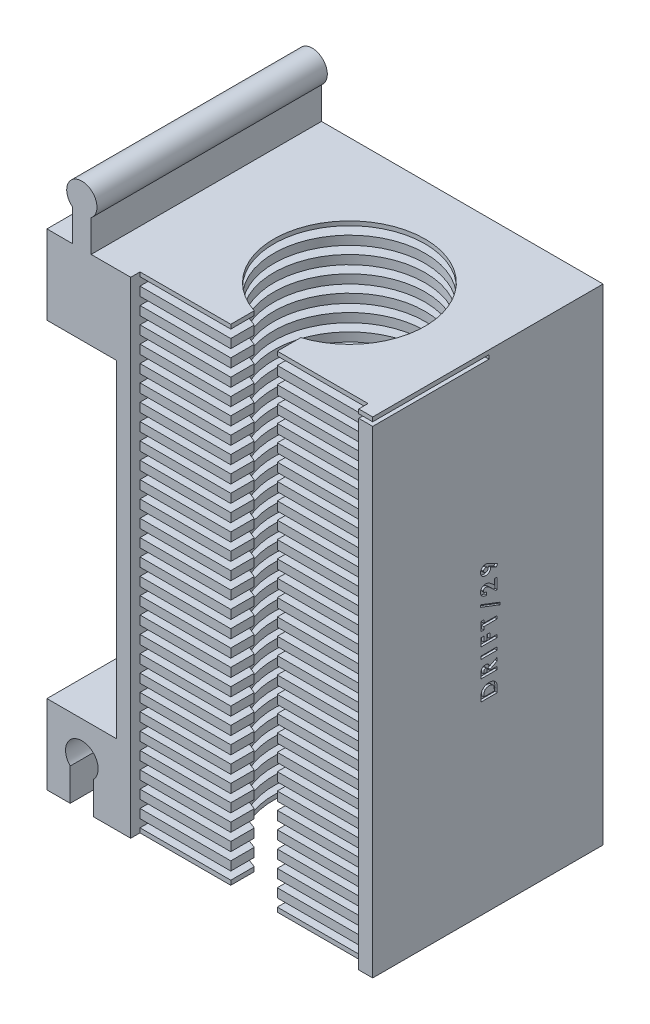
from build123d import *

# Parameters (mm, degrees)
ESQUISSE1_W              = 55
ESQUISSE1_H              = 106.55
BOSS_EXTRU_2_DEPTH       = 49.5
ESQUISSE6_W              = 49
ESQUISSE6_H              = 101.75
ENL_V_MAT_EXTRU_2_DEPTH  = 47
ESQUISSE7_W              = 49
ESQUISSE7_H              = 1.9
BOSS_EXTRU_3_DEPTH       = 45
ESQUISSE8_R              = 16.25
ENL_V_MAT_EXTRU_4_DEPTH  = 107.55
ESQUISSE9_W              = 10
ESQUISSE9_H              = 5.038353904
ENL_V_MAT_EXTRU_5_DEPTH  = 107.55
ESQUISSE11_W             = 55
ESQUISSE11_H             = 49.5
ENL_V_MAT_EXTRU_6_DEPTH  = 4.8
ESQUISSE14_W             = 15
ESQUISSE14_H             = 17.95
BOSS_EXTRU_5_DEPTH       = 49.5
ESQUISSE15_W             = 15
ESQUISSE15_H             = 17.95
BOSS_EXTRU_6_DEPTH       = 49.5
ESQUISSE16_W             = 15
ESQUISSE16_H             = 17
BOSS_EXTRU_7_DEPTH       = 49.5
ESQUISSE17_W             = 15
ESQUISSE17_H             = 17
BOSS_EXTRU_8_DEPTH       = 49.5
ENL_V_MAT_EXTRU_8_DEPTH  = 50.5
BOSS_EXTRU_9_DEPTH       = 49.5
ENL_V_MAT_EXTRU_10_DEPTH = 0.95
ESQUISSE22_W             = 5
ESQUISSE22_H             = 49.5
ENL_V_MAT_EXTRU_11_DEPTH = 0.95
BOSS_EXTRU_10_DEPTH      = 3.6
ESQUISSE24_W             = 49
ESQUISSE24_H             = 1.7
ENL_V_MAT_EXTRU_12_DEPTH = 45
ESQUISSE25_W             = 15
ESQUISSE25_H             = 49.5
ENL_V_MAT_EXTRU_13_DEPTH = 3.6
ESQUISSE26_W             = 5.5
ESQUISSE26_H             = 49.5
BOSS_EXTRU_11_DEPTH      = 3.6
ESQUISSE27_W             = 3.5
ESQUISSE27_H             = 0.628205128
ENL_V_MAT_EXTRU_15_DEPTH = 0.5
ESQUISSE28_W             = 15
ESQUISSE28_H             = 49.5
ENL_V_MAT_EXTRU_16_DEPTH = 18
ESQUISSE29_W             = 15
ESQUISSE29_H             = 49.5
ENL_V_MAT_EXTRU_17_DEPTH = 30.651737691
ENL_V_MAT_EXTRU_18_DEPTH = 0.05
ESQUISSE31_W             = 25
ESQUISSE31_H             = 0.85
ENL_V_MAT_EXTRU_19_DEPTH = 4.0000001


with BuildPart() as part:
    # Esquisse1 → Boss.-Extru.2 (new body)
    with BuildSketch(Plane.XY):
        with Locations((7.352262443, -28.968325792)):
            Rectangle(ESQUISSE1_W, ESQUISSE1_H)
    extrude(amount=BOSS_EXTRU_2_DEPTH)

    # Esquisse6 → Enlèv. mat.-Extru.2 (cut)
    with BuildSketch(Plane.XY.offset(49.5)):
        with Locations((7.352262443, -31.368325792)):
            Rectangle(ESQUISSE6_W, ESQUISSE6_H)
    extrude(amount=-ENL_V_MAT_EXTRU_2_DEPTH, mode=Mode.SUBTRACT)

    # Esquisse7 → Boss.-Extru.3 (add)
    with BuildSketch(Plane.XY.offset(2.5)):
        with Locations((7.352262443, -81.293325792)):
            Rectangle(ESQUISSE7_W, ESQUISSE7_H)
        with Locations((7.352262443, -77.693325792)):
            Rectangle(ESQUISSE7_W, ESQUISSE7_H)
        with Locations((7.352262443, -74.093325792)):
            Rectangle(ESQUISSE7_W, ESQUISSE7_H)
        with Locations((7.352262443, -70.493325792)):
            Rectangle(ESQUISSE7_W, ESQUISSE7_H)
        with Locations((7.352262443, -66.893325792)):
            Rectangle(ESQUISSE7_W, ESQUISSE7_H)
        with Locations((7.352262443, -63.293325792)):
            Rectangle(ESQUISSE7_W, ESQUISSE7_H)
        with Locations((7.352262443, -59.693325792)):
            Rectangle(ESQUISSE7_W, ESQUISSE7_H)
        with Locations((7.352262443, -56.093325792)):
            Rectangle(ESQUISSE7_W, ESQUISSE7_H)
        with Locations((7.352262443, -52.493325792)):
            Rectangle(ESQUISSE7_W, ESQUISSE7_H)
        with Locations((7.352262443, -48.893325792)):
            Rectangle(ESQUISSE7_W, ESQUISSE7_H)
        with Locations((7.352262443, -45.293325792)):
            Rectangle(ESQUISSE7_W, ESQUISSE7_H)
        with Locations((7.352262443, -41.693325792)):
            Rectangle(ESQUISSE7_W, ESQUISSE7_H)
        with Locations((7.352262443, -38.093325792)):
            Rectangle(ESQUISSE7_W, ESQUISSE7_H)
        with Locations((7.352262443, -34.493325792)):
            Rectangle(ESQUISSE7_W, ESQUISSE7_H)
        with Locations((7.352262443, -30.893325792)):
            Rectangle(ESQUISSE7_W, ESQUISSE7_H)
        with Locations((7.352262443, -27.293325792)):
            Rectangle(ESQUISSE7_W, ESQUISSE7_H)
        with Locations((7.352262443, -23.693325792)):
            Rectangle(ESQUISSE7_W, ESQUISSE7_H)
        with Locations((7.352262443, -20.093325792)):
            Rectangle(ESQUISSE7_W, ESQUISSE7_H)
        with Locations((7.352262443, -16.493325792)):
            Rectangle(ESQUISSE7_W, ESQUISSE7_H)
        with Locations((7.352262443, -12.893325792)):
            Rectangle(ESQUISSE7_W, ESQUISSE7_H)
        with Locations((7.352262443, -9.293325792)):
            Rectangle(ESQUISSE7_W, ESQUISSE7_H)
        with Locations((7.352262443, -5.693325792)):
            Rectangle(ESQUISSE7_W, ESQUISSE7_H)
        with Locations((7.352262443, -2.093325792)):
            Rectangle(ESQUISSE7_W, ESQUISSE7_H)
        with Locations((7.352262443, 1.506674208)):
            Rectangle(ESQUISSE7_W, ESQUISSE7_H)
        with Locations((7.352262443, 5.106674208)):
            Rectangle(ESQUISSE7_W, ESQUISSE7_H)
        with Locations((7.352262443, 8.706674208)):
            Rectangle(ESQUISSE7_W, ESQUISSE7_H)
        with Locations((7.352262443, 12.306674208)):
            Rectangle(ESQUISSE7_W, ESQUISSE7_H)
        with Locations((7.352262443, 15.906674208)):
            Rectangle(ESQUISSE7_W, ESQUISSE7_H)
        with Locations((7.352262443, 19.506674208)):
            Rectangle(ESQUISSE7_W, ESQUISSE7_H)
    extrude(amount=BOSS_EXTRU_3_DEPTH)

    # Esquisse8 → Enlèv. mat.-Extru.4 (cut, through all)
    with BuildSketch(Plane.XZ.offset(82.243325792)):
        with Locations((7.352262443, 27)):
            Circle(ESQUISSE8_R)
    extrude(amount=-ENL_V_MAT_EXTRU_4_DEPTH, mode=Mode.SUBTRACT)

    # Esquisse9 → Enlèv. mat.-Extru.5 (cut, through all)
    with BuildSketch(Plane.XZ.offset(82.243325792)):
        with Locations((7.352262443, 44.980823048)):
            Rectangle(ESQUISSE9_W, ESQUISSE9_H)
    extrude(amount=-ENL_V_MAT_EXTRU_5_DEPTH, mode=Mode.SUBTRACT)

    # Esquisse11 → Enlèv. mat.-Extru.6 (cut)
    with BuildSketch(Plane(origin=(0, 24.306674208, 0), x_dir=(1, 0, 0), z_dir=(0, 1, 0))):
        with Locations((7.352262443, -24.75)):
            Rectangle(ESQUISSE11_W, ESQUISSE11_H)
    extrude(amount=-ENL_V_MAT_EXTRU_6_DEPTH, mode=Mode.SUBTRACT)

    # Esquisse14 → Boss.-Extru.5 (add)
    with BuildSketch(Plane.XY.offset(49.5)):
        with Locations((42.352262443, -73.268325792)):
            Rectangle(ESQUISSE14_W, ESQUISSE14_H)
    extrude(amount=-BOSS_EXTRU_5_DEPTH)

    # Esquisse15 → Boss.-Extru.6 (add)
    with BuildSketch(Plane.XY.offset(49.5)):
        with Locations((-27.647737557, -73.268325792)):
            Rectangle(ESQUISSE15_W, ESQUISSE15_H)
    extrude(amount=-BOSS_EXTRU_6_DEPTH)

    # Esquisse16 → Boss.-Extru.7 (add)
    with BuildSketch(Plane.XY.offset(49.5)):
        with Locations((42.352262443, 11.006674208)):
            Rectangle(ESQUISSE16_W, ESQUISSE16_H)
    extrude(amount=-BOSS_EXTRU_7_DEPTH)

    # Esquisse17 → Boss.-Extru.8 (add)
    with BuildSketch(Plane.XY.offset(49.5)):
        with Locations((-27.647737557, 11.006674208)):
            Rectangle(ESQUISSE17_W, ESQUISSE17_H)
    extrude(amount=-BOSS_EXTRU_8_DEPTH)

    # Esquisse18 → Enlèv. mat.-Extru.8 (cut, through all)
    with BuildSketch(Plane.XY.offset(49.5)):
        with BuildLine():
            Line((44.852262443, -74.343325792), (44.852262443, -82.243325792))
            Line((44.852262443, -82.243325792), (39.852262443, -82.243325792))
            Line((39.852262443, -82.243325792), (39.852262443, -74.343325792))
            ThreePointArc((39.852262443, -74.343325792), (42.352262443, -68.393836049), (44.852262443, -74.343325792))
        make_face()
        with BuildLine():
            Line((-30.147737557, -82.243325792), (-25.147737557, -82.243325792))
            Line((-25.147737557, -82.243325792), (-25.147737557, -74.343325792))
            ThreePointArc((-25.147737557, -74.343325792), (-27.647737557, -68.393836049), (-30.147737557, -74.343325792))
            Line((-30.147737557, -74.343325792), (-30.147737557, -82.243325792))
        make_face()
    extrude(amount=-ENL_V_MAT_EXTRU_8_DEPTH, mode=Mode.SUBTRACT)

    # Esquisse20 → Boss.-Extru.9 (add)
    with BuildSketch(Plane.XY.offset(49.5)):
        with BuildLine():
            Line((-29.647737557, 29.946674208), (-29.647737557, 19.506674208))
            Line((-29.647737557, 19.506674208), (-25.647737557, 19.506674208))
            Line((-25.647737557, 19.506674208), (-25.647737557, 29.946674208))
            ThreePointArc((-25.647737557, 29.946674208), (-27.647737557, 35.7584119), (-29.647737557, 29.946674208))
        make_face()
        with BuildLine():
            Line((40.352262443, 19.506674208), (40.352262443, 29.946674208))
            ThreePointArc((40.352262443, 29.946674208), (42.352262443, 35.7584119), (44.352262443, 29.946674208))
            Line((44.352262443, 29.946674208), (44.352262443, 19.506674208))
            Line((44.352262443, 19.506674208), (40.352262443, 19.506674208))
        make_face()
    extrude(amount=-BOSS_EXTRU_9_DEPTH)

    # Esquisse10 → Enlèv. mat.-Extru.10 (cut)
    with BuildSketch(Plane.XZ.offset(82.243325792)):
        with BuildLine():
            Line((31.852262443, 47.5), (12.352262443, 47.5))
            Line((12.352262443, 47.5), (12.352262443, 42.461646096))
            ThreePointArc((12.352262443, 42.461646096), (7.352262443, 10.75), (2.352262443, 42.461646096))
            Line((2.352262443, 42.461646096), (2.352262443, 47.5))
            Line((2.352262443, 47.5), (-17.147737557, 47.5))
            Line((-17.147737557, 47.5), (-17.147737557, 49.5))
            Line((-17.147737557, 49.5), (-20.147737557, 49.5))
            Line((-20.147737557, 49.5), (-20.147737557, 0))
            Line((-20.147737557, 0), (34.852262443, 0))
            Line((34.852262443, 0), (34.852262443, 49.5))
            Line((34.852262443, 49.5), (31.852262443, 49.5))
            Line((31.852262443, 49.5), (31.852262443, 47.5))
        make_face()
    extrude(amount=-ENL_V_MAT_EXTRU_10_DEPTH, mode=Mode.SUBTRACT)

    # Esquisse22 → Enlèv. mat.-Extru.11 (cut)
    with BuildSketch(Plane.XZ.offset(82.243325792)):
        with Locations((47.352262443, 24.75)):
            Rectangle(ESQUISSE22_W, ESQUISSE22_H)
        with Locations((37.352262443, 24.75)):
            Rectangle(ESQUISSE22_W, ESQUISSE22_H)
        with Locations((-32.647737557, 24.75)):
            Rectangle(ESQUISSE22_W, ESQUISSE22_H)
        with Locations((-22.647737557, 24.75)):
            Rectangle(ESQUISSE22_W, ESQUISSE22_H)
    extrude(amount=-ENL_V_MAT_EXTRU_11_DEPTH, mode=Mode.SUBTRACT)

    # Esquisse23 → Boss.-Extru.10 (add)
    with BuildSketch(Plane(origin=(0, 19.506674208, 0), x_dir=(1, 0, 0), z_dir=(0, 1, 0))):
        with BuildLine():
            Line((40.352262443, -49.5), (40.352262443, 0))
            Line((40.352262443, 0), (-25.647737557, 0))
            Line((-25.647737557, 0), (-25.647737557, -49.5))
            Line((-25.647737557, -49.5), (-17.147737557, -49.5))
            Line((-17.147737557, -49.5), (-17.147737557, -47.5))
            Line((-17.147737557, -47.5), (2.352262443, -47.5))
            Line((2.352262443, -47.5), (2.352262443, -42.461646096))
            ThreePointArc((2.352262443, -42.461646096), (7.352262443, -10.75), (12.352262443, -42.461646096))
            Line((12.352262443, -42.461646096), (12.352262443, -47.5))
            Line((12.352262443, -47.5), (31.852262443, -47.5))
            Line((31.852262443, -47.5), (31.852262443, -49.5))
            Line((31.852262443, -49.5), (40.352262443, -49.5))
        make_face()
    extrude(amount=BOSS_EXTRU_10_DEPTH)

    # Esquisse24 → Enlèv. mat.-Extru.12 (cut)
    with BuildSketch(Plane.XY.offset(47.5)):
        with Locations((7.352262443, 21.306674208)):
            Rectangle(ESQUISSE24_W, ESQUISSE24_H)
    extrude(amount=-ENL_V_MAT_EXTRU_12_DEPTH, mode=Mode.SUBTRACT)

    # Esquisse25 → Enlèv. mat.-Extru.13 (cut)
    with BuildSketch(Plane.XZ.offset(-2.506674208)):
        with Locations((-27.647737557, 24.75)):
            Rectangle(ESQUISSE25_W, ESQUISSE25_H)
        with Locations((42.352262443, 24.75)):
            Rectangle(ESQUISSE25_W, ESQUISSE25_H)
    extrude(amount=-ENL_V_MAT_EXTRU_13_DEPTH, mode=Mode.SUBTRACT)

    # Esquisse26 → Boss.-Extru.11 (add)
    with BuildSketch(Plane(origin=(0, 19.506674208, 0), x_dir=(1, 0, 0), z_dir=(0, 1, 0))):
        with Locations((-32.397737557, -24.75)):
            Rectangle(ESQUISSE26_W, ESQUISSE26_H)
        with Locations((47.102262443, -24.75)):
            Rectangle(ESQUISSE26_W, ESQUISSE26_H)
    extrude(amount=BOSS_EXTRU_11_DEPTH)

    # Esquisse27 → Enlèv. mat.-Extru.15 (cut)
    with BuildSketch(Plane(origin=(34.852262443, 0, 0), x_dir=(0, 0, -1), z_dir=(1, 0, 0))):
        with BuildLine():
            Line((-26.25, -41.581146305), (-26.25, -40.789579798))
            add(Edge.make_bspline(
                [(-26.25, -40.789579798), (-26.249578594, -40.727866572), (-26.248764011, -40.608574207), (-26.239233964, -40.435767762), (-26.225241045, -40.274959028), (-26.203820297, -40.126514303), (-26.178974202, -39.989890609), (-26.145644783, -39.866124289), (-26.107640591, -39.754317891), (-26.062804681, -39.65338554), (-26.010558183, -39.561239848), (-25.952352997, -39.473745665), (-25.886064826, -39.391073342), (-25.812970397, -39.312063093), (-25.731733047, -39.237734455), (-25.643698202, -39.166849619), (-25.547589281, -39.101144161), (-25.445710659, -39.038631948), (-25.337630589, -38.98209797), (-25.224269024, -38.932786922), (-25.106355489, -38.891478757), (-24.983764318, -38.857913735), (-24.856902477, -38.831158538), (-24.72551397, -38.812438466), (-24.589720442, -38.800865531), (-24.4976865, -38.799691554), (-24.450921474, -38.799095023)],
                knots=[0, 0, 0, 0, 0.000185117, 0.000357834, 0.000519065, 0.000669183, 0.000807653, 0.000935374, 0.001053334, 0.001161611, 0.001266144, 0.001370762, 0.001476536, 0.001583695, 0.001693351, 0.00180657, 0.001922483, 0.002042366, 0.002164984, 0.002288073, 0.002412914, 0.002539466, 0.002669135, 0.002801605, 0.002937385, 0.003077654, 0.003077654, 0.003077654, 0.003077654], degree=3))
            add(Edge.make_bspline(
                [(-24.450921474, -38.799095023), (-24.384932979, -38.800657062), (-24.255030763, -38.803732029), (-24.064400757, -38.829633833), (-23.881662884, -38.87152582), (-23.708246589, -38.930429758), (-23.545696172, -39.003454873), (-23.396878133, -39.09069155), (-23.262591281, -39.190860698), (-23.143504152, -39.302795331), (-23.04114743, -39.423993307), (-22.953485402, -39.549942339), (-22.884360039, -39.681869876), (-22.840513664, -39.79811532), (-22.813270001, -39.898917402), (-22.797083391, -39.987411224), (-22.782639367, -40.087999175), (-22.769738179, -40.201348242), (-22.761139953, -40.327447269), (-22.755119024, -40.466317598), (-22.750668347, -40.617777023), (-22.75022862, -40.722969702), (-22.75, -40.777660728)],
                knots=[0, 0, 0, 0, 0.000197895, 0.000389568, 0.000575968, 0.000759549, 0.000938093, 0.001109685, 0.001275991, 0.00143967, 0.001598838, 0.001751113, 0.001899136, 0.002044464, 0.002122868, 0.002212109, 0.002314138, 0.002427722, 0.002554253, 0.002693218, 0.002844719, 0.003008787, 0.003008787, 0.003008787, 0.003008787], degree=3))
            Line((-22.75, -40.777660728), (-22.75, -41.581146305))
            Line((-22.75, -41.581146305), (-26.25, -41.581146305))
        make_face()
        with BuildLine():
            Line((-25.621794872, -40.952941176), (-23.378205128, -40.952941176))
            Line((-23.378205128, -40.952941176), (-23.378205128, -40.624816176))
            add(Edge.make_bspline(
                [(-23.378205128, -40.624816176), (-23.378394152, -40.58578111), (-23.378757652, -40.51071505), (-23.383752105, -40.402204241), (-23.391862503, -40.302063523), (-23.403859003, -40.210161726), (-23.418293863, -40.126287573), (-23.436147882, -40.050747014), (-23.457859729, -39.983391161), (-23.483447361, -39.923664568), (-23.512661318, -39.869135507), (-23.546774213, -39.818618742), (-23.584684458, -39.769863909), (-23.627472703, -39.723772091), (-23.674581701, -39.680171713), (-23.726251594, -39.639319951), (-23.782325449, -39.60067176), (-23.843099544, -39.565219106), (-23.907932147, -39.532822285), (-23.976195242, -39.504082673), (-24.04845732, -39.480253294), (-24.124041919, -39.460447773), (-24.20360709, -39.446294483), (-24.286563503, -39.434585335), (-24.373239826, -39.428548928), (-24.432217292, -39.427720468), (-24.462139423, -39.427300151)],
                knots=[0, 0, 0, 0, 0.000117096, 0.00022518, 0.000325793, 0.00041841, 0.000503133, 0.000581017, 0.00065108, 0.000715155, 0.0007757, 0.00083637, 0.000897801, 0.000960813, 0.001024815, 0.001090185, 0.001158251, 0.001228957, 0.001301074, 0.001375555, 0.001450937, 0.001529162, 0.001609745, 0.001693235, 0.001780402, 0.001870171, 0.001870171, 0.001870171, 0.001870171], degree=3))
            add(Edge.make_bspline(
                [(-24.462139423, -39.427300151), (-24.507993301, -39.428134279), (-24.597404811, -39.429760763), (-24.727617239, -39.445544279), (-24.850078276, -39.470976128), (-24.964473331, -39.508023303), (-25.071529664, -39.55358164), (-25.169867721, -39.611510018), (-25.261099367, -39.678289281), (-25.314608967, -39.731127033), (-25.341346154, -39.757528516)],
                knots=[0, 0, 0, 0, 0.000137507, 0.000268129, 0.000392852, 0.000512141, 0.000628325, 0.00074112, 0.000853862, 0.000966454, 0.000966454, 0.000966454, 0.000966454], degree=3))
            add(Edge.make_bspline(
                [(-25.341346154, -39.757528516), (-25.364130624, -39.78356071), (-25.410665325, -39.836728519), (-25.466425797, -39.93007372), (-25.515416837, -40.032935296), (-25.554261268, -40.147666414), (-25.584981101, -40.273158246), (-25.606167818, -40.410158225), (-25.619782177, -40.557932687), (-25.6211096, -40.660307391), (-25.621794872, -40.713157523)],
                knots=[0, 0, 0, 0, 0.000103595, 0.000211582, 0.000324802, 0.000444978, 0.000574215, 0.000711958, 0.000860493, 0.001019003, 0.001019003, 0.001019003, 0.001019003], degree=3))
            Line((-25.621794872, -40.713157523), (-25.621794872, -40.952941176))
        make_face(mode=Mode.SUBTRACT)
        with BuildLine():
            Line((-26.25, -37.282428356), (-26.25, -36.550457202))
            add(Edge.make_bspline(
                [(-26.25, -36.550457202), (-26.249830799, -36.502073773), (-26.249505379, -36.409018811), (-26.244260781, -36.274844373), (-26.237121633, -36.151566425), (-26.225691304, -36.039123585), (-26.212215771, -35.937242739), (-26.194650202, -35.846250405), (-26.175000792, -35.765859992), (-26.150417474, -35.695491615), (-26.122731795, -35.631966658), (-26.090826593, -35.572820332), (-26.055389952, -35.51630623), (-26.014127668, -35.464245593), (-25.970721386, -35.413594739), (-25.922243734, -35.366847166), (-25.869536803, -35.323199687), (-25.812611126, -35.283440271), (-25.752669787, -35.246877876), (-25.689495986, -35.215426874), (-25.623603594, -35.18861171), (-25.55531745, -35.1660803), (-25.48395642, -35.149280821), (-25.410334289, -35.137777485), (-25.334062078, -35.12931373), (-25.282242845, -35.12882931), (-25.255809295, -35.128582202)],
                knots=[0, 0, 0, 0, 0.000145139, 0.000279143, 0.000402781, 0.00051552, 0.000618146, 0.000710961, 0.000793435, 0.000866163, 0.000934291, 0.001001103, 0.001067621, 0.001134095, 0.001200183, 0.001267615, 0.00133584, 0.001405283, 0.001475745, 0.001546294, 0.001616731, 0.001689011, 0.001761797, 0.001836373, 0.001912486, 0.001991741, 0.001991741, 0.001991741, 0.001991741], degree=3))
            add(Edge.make_bspline(
                [(-25.255809295, -35.128582202), (-25.228219651, -35.129228459), (-25.174121389, -35.13049565), (-25.09464501, -35.137264844), (-25.018423209, -35.14984957), (-24.945945132, -35.16828982), (-24.876468478, -35.190361715), (-24.811077599, -35.218946946), (-24.748615739, -35.251452755), (-24.69011221, -35.290015187), (-24.634309754, -35.332362224), (-24.583235096, -35.381543289), (-24.534467089, -35.434779455), (-24.489666455, -35.493690732), (-24.449112087, -35.558100747), (-24.411156725, -35.626798332), (-24.376474519, -35.700732889), (-24.357075547, -35.752666047), (-24.347155449, -35.779223228)],
                knots=[0, 0, 0, 0, 8.278e-05, 0.000162316, 0.000239082, 0.000314243, 0.000386523, 0.000457503, 0.000528069, 0.000597494, 0.000667473, 0.0007379, 0.00080987, 0.000883911, 0.00095957, 0.001038021, 0.00111926, 0.001204281, 0.001204281, 0.001204281, 0.001204281], degree=3))
            Line((-24.347155449, -35.779223228), (-22.75, -34.97153092))
            Line((-22.75, -34.97153092), (-22.75, -35.669848228))
            Line((-22.75, -35.669848228), (-24.275641026, -36.441082202))
            Line((-24.275641026, -36.441082202), (-24.275641026, -36.654223228))
            Line((-24.275641026, -36.654223228), (-22.75, -36.654223228))
            Line((-22.75, -36.654223228), (-22.75, -37.282428356))
            Line((-22.75, -37.282428356), (-26.25, -37.282428356))
        make_face()
        with BuildLine():
            Line((-24.903846154, -36.654223228), (-24.903846154, -36.409531721))
            add(Edge.make_bspline(
                [(-24.903846154, -36.409531721), (-24.904183083, -36.379616151), (-24.90482823, -36.322334261), (-24.90782069, -36.23995538), (-24.91503104, -36.16513571), (-24.924141047, -36.097553949), (-24.934659866, -36.036870034), (-24.949733972, -35.983625241), (-24.965886258, -35.936999152), (-24.98595936, -35.897544286), (-25.008786831, -35.863834955), (-25.034719405, -35.834729105), (-25.064733058, -35.810654394), (-25.098012147, -35.790839679), (-25.134851019, -35.775425985), (-25.174845265, -35.764175169), (-25.218450472, -35.757887627), (-25.248544002, -35.757164224), (-25.264222756, -35.75678733)],
                knots=[0, 0, 0, 0, 8.9755e-05, 0.000171861, 0.000247208, 0.00031513, 0.000376461, 0.000431743, 0.000480981, 0.000524253, 0.000564118, 0.000602839, 0.000640725, 0.000679082, 0.000718669, 0.000760178, 0.000803409, 0.000850432, 0.000850432, 0.000850432, 0.000850432], degree=3))
            add(Edge.make_bspline(
                [(-25.264222756, -35.75678733), (-25.282782236, -35.75746504), (-25.319012094, -35.758787993), (-25.371317394, -35.773092042), (-25.420078854, -35.794676764), (-25.464634662, -35.825227883), (-25.503578199, -35.863365199), (-25.537980978, -35.907143325), (-25.564881405, -35.957701924), (-25.583771508, -36.004055195), (-25.594375064, -36.046626009), (-25.602337473, -36.084913504), (-25.608254131, -36.129211699), (-25.613043563, -36.179745066), (-25.617318759, -36.236067241), (-25.6200393, -36.298730003), (-25.621237585, -36.367459739), (-25.621603761, -36.415374092), (-25.621794872, -36.44038108)],
                knots=[0, 0, 0, 0, 5.5548e-05, 0.000108435, 0.000161471, 0.000214949, 0.000269493, 0.000324467, 0.000381263, 0.000440763, 0.000474094, 0.000512732, 0.000558045, 0.000608066, 0.000665013, 0.000727476, 0.0007962, 0.000871223, 0.000871223, 0.000871223, 0.000871223], degree=3))
            Line((-25.621794872, -36.44038108), (-25.621794872, -36.654223228))
            Line((-25.621794872, -36.654223228), (-24.903846154, -36.654223228))
        make_face(mode=Mode.SUBTRACT)
        with Locations((-24.5, -33.342684766)):
            Rectangle(ESQUISSE27_W, ESQUISSE27_H)
        Polygon((-26.25, -31.332428356), (-26.25, -29.627300151), (-25.621794872, -29.627300151), (-25.621794872, -30.704223228), (-24.948717949, -30.704223228), (-24.948717949, -29.627300151), (-24.320512821, -29.627300151), (-24.320512821, -30.704223228), (-22.75, -30.704223228), (-22.75, -31.332428356), align=None)
        Polygon((-26.25, -28.469607843), (-26.25, -26.584992459), (-25.621794872, -26.584992459), (-25.621794872, -27.213197587), (-22.75, -27.213197587), (-22.75, -27.841402715), (-25.621794872, -27.841402715), (-25.621794872, -28.469607843), align=None)
        Polygon((-22.121794872, -25.517043741), (-26.33974359, -23.906566978), (-26.33974359, -23.430505279), (-22.121794872, -25.040982042), align=None)
        with BuildLine():
            Line((-25.083333333, -21.667043741), (-25.083333333, -22.295248869))
            add(Edge.make_bspline(
                [(-25.083333333, -22.295248869), (-25.130854225, -22.292536812), (-25.223707194, -22.287237617), (-25.358570766, -22.266135637), (-25.486033191, -22.237932364), (-25.605711269, -22.199970061), (-25.717655278, -22.153210969), (-25.821494412, -22.096491307), (-25.917972725, -22.031504524), (-26.00539818, -21.956940687), (-26.083996324, -21.875825983), (-26.152708884, -21.788368361), (-26.210230283, -21.694816257), (-26.257415349, -21.595795232), (-26.295169479, -21.49169423), (-26.320397882, -21.381461457), (-26.337486499, -21.266069573), (-26.33898158, -21.187073784), (-26.33974359, -21.146811369)],
                knots=[0, 0, 0, 0, 0.000142716, 0.000278858, 0.000408976, 0.000534035, 0.000655007, 0.000772346, 0.00088844, 0.001003349, 0.001116402, 0.001226781, 0.001336329, 0.001445148, 0.001555367, 0.001667776, 0.001783885, 0.001904578, 0.001904578, 0.001904578, 0.001904578], degree=3))
            add(Edge.make_bspline(
                [(-26.33974359, -21.146811369), (-26.338305172, -21.097367632), (-26.335495808, -21.000799457), (-26.308364005, -20.860944651), (-26.266816094, -20.72962898), (-26.206452711, -20.608249272), (-26.130333998, -20.497016559), (-26.039398207, -20.396549259), (-25.932540626, -20.308806804), (-25.81283848, -20.234473483), (-25.685837603, -20.173003744), (-25.55475327, -20.1295149), (-25.422968709, -20.101080766), (-25.33424216, -20.098041017), (-25.290164263, -20.09653092)],
                knots=[0, 0, 0, 0, 0.000148176, 0.000289401, 0.00042576, 0.000560275, 0.000694458, 0.000828966, 0.000965417, 0.001107812, 0.001250813, 0.001387611, 0.0015214, 0.001653479, 0.001653479, 0.001653479, 0.001653479], degree=3))
            add(Edge.make_bspline(
                [(-25.290164263, -20.09653092), (-25.263502321, -20.097118118), (-25.209838418, -20.098300003), (-25.12863176, -20.106517803), (-25.045913288, -20.118846131), (-24.961753913, -20.13743423), (-24.876130087, -20.160615167), (-24.788785397, -20.188736785), (-24.70021573, -20.222452389), (-24.609421581, -20.261195438), (-24.516118882, -20.307429039), (-24.41886483, -20.361207989), (-24.317762959, -20.42433024), (-24.211821602, -20.494740972), (-24.102658361, -20.575210161), (-23.989061065, -20.663606255), (-23.87120871, -20.760374217), (-23.792395337, -20.829000737), (-23.751903045, -20.864259285)],
                knots=[0, 0, 0, 0, 7.9977e-05, 0.000160974, 0.000244663, 0.00033075, 0.000419361, 0.000510712, 0.000605902, 0.000703579, 0.00080674, 0.00091815, 0.001036838, 0.001164207, 0.001299674, 0.001443567, 0.001595999, 0.001757068, 0.001757068, 0.001757068, 0.001757068], degree=3))
            Line((-23.751903045, -20.864259285), (-23.333333333, -21.229543741))
            Line((-23.333333333, -21.229543741), (-23.333333333, -20.051659125))
            Line((-23.333333333, -20.051659125), (-22.75, -20.051659125))
            Line((-22.75, -20.051659125), (-22.75, -22.384992459))
            Line((-22.75, -22.384992459), (-23.068309295, -22.384992459))
            Line((-23.068309295, -22.384992459), (-24.171173878, -21.348734446))
            add(Edge.make_bspline(
                [(-24.171173878, -21.348734446), (-24.20334446, -21.318731638), (-24.265649338, -21.260625097), (-24.357155907, -21.177953194), (-24.443974712, -21.103114892), (-24.527112566, -21.037783566), (-24.603754527, -20.978006482), (-24.676797956, -20.927998555), (-24.74418582, -20.884447778), (-24.826328946, -20.83895439), (-24.923559297, -20.79475636), (-25.035503417, -20.754227471), (-25.142571242, -20.729769954), (-25.212463844, -20.726368051), (-25.24599359, -20.724736048)],
                knots=[0, 0, 0, 0, 0.000131967, 0.000255582, 0.000369957, 0.000475731, 0.00057277, 0.000661456, 0.000741202, 0.000813387, 0.000942958, 0.001061149, 0.001170202, 0.001270758, 0.001270758, 0.001270758, 0.001270758], degree=3))
            add(Edge.make_bspline(
                [(-25.24599359, -20.724736048), (-25.278432191, -20.725953037), (-25.341287182, -20.728311149), (-25.430698073, -20.754224882), (-25.511650506, -20.794371336), (-25.581725534, -20.850943361), (-25.639310831, -20.9194698), (-25.682141156, -20.998658538), (-25.706854058, -21.087863952), (-25.709947231, -21.150398648), (-25.711538462, -21.18256858)],
                knots=[0, 0, 0, 0, 9.7062e-05, 0.000188073, 0.000276808, 0.000366596, 0.000456186, 0.000543702, 0.000634713, 0.000731135, 0.000731135, 0.000731135, 0.000731135], degree=3))
            add(Edge.make_bspline(
                [(-25.711538462, -21.18256858), (-25.710950642, -21.199187977), (-25.709793424, -21.231905929), (-25.702090139, -21.279998761), (-25.688513903, -21.325762546), (-25.670323658, -21.36970666), (-25.646212358, -21.41136212), (-25.616491338, -21.450623858), (-25.581915879, -21.487905546), (-25.542594092, -21.523036195), (-25.498710967, -21.555009672), (-25.450667285, -21.583408397), (-25.39849287, -21.606889415), (-25.342876502, -21.627562956), (-25.283220817, -21.643507381), (-25.219882848, -21.6551169), (-25.152965636, -21.663942842), (-25.106966346, -21.665991304), (-25.083333333, -21.667043741)],
                knots=[0, 0, 0, 0, 4.9859e-05, 9.8155e-05, 0.000145635, 0.000192772, 0.000240515, 0.000289593, 0.000340201, 0.000392836, 0.000447528, 0.000502841, 0.000559939, 0.000618941, 0.00068068, 0.000744897, 0.000812032, 0.000882971, 0.000882971, 0.000882971, 0.000882971], degree=3))
        make_face()
        with BuildLine():
            Line((-22.66025641, -17.57866233), (-22.940705128, -18.135353035))
            Line((-22.940705128, -18.135353035), (-24.141025641, -17.525377074))
            add(Edge.make_bspline(
                [(-24.141025641, -17.525377074), (-24.141944291, -17.561415799), (-24.143747823, -17.632168535), (-24.158733038, -17.736347365), (-24.18431911, -17.835967411), (-24.218362242, -17.932220218), (-24.264069316, -18.023710252), (-24.318440512, -18.111914848), (-24.384763371, -18.194530917), (-24.458199348, -18.273537069), (-24.539588601, -18.345004187), (-24.626551539, -18.408121608), (-24.718251162, -18.461566944), (-24.815303675, -18.504470612), (-24.916741872, -18.538167336), (-25.022963667, -18.563020505), (-25.134377636, -18.576925551), (-25.21019924, -18.578872905), (-25.248798077, -18.579864253)],
                knots=[0, 0, 0, 0, 0.000108084, 0.000212196, 0.000314904, 0.000416257, 0.00051785, 0.000621153, 0.000726492, 0.00083512, 0.00094441, 0.001050856, 0.00115704, 0.001262185, 0.001368608, 0.001477284, 0.001588945, 0.001704735, 0.001704735, 0.001704735, 0.001704735], degree=3))
            add(Edge.make_bspline(
                [(-25.248798077, -18.579864253), (-25.286239523, -18.578946589), (-25.360017117, -18.577138349), (-25.468290116, -18.562091079), (-25.572280734, -18.537400713), (-25.672017607, -18.503201324), (-25.766992878, -18.458665992), (-25.85777246, -18.404858787), (-25.944009135, -18.340978179), (-26.024579069, -18.267548644), (-26.098627223, -18.187989068), (-26.162357853, -18.102397355), (-26.217982113, -18.014066622), (-26.261929693, -17.920567116), (-26.297648374, -17.823635907), (-26.321801472, -17.721940076), (-26.33702242, -17.616518615), (-26.338829275, -17.544827624), (-26.33974359, -17.508550151)],
                knots=[0, 0, 0, 0, 0.000112287, 0.000221259, 0.000327205, 0.000432525, 0.000536976, 0.000641346, 0.00074862, 0.00085832, 0.000967976, 0.001074126, 0.001178025, 0.001280573, 0.001383483, 0.001487384, 0.001593578, 0.001702362, 0.001702362, 0.001702362, 0.001702362], degree=3))
            add(Edge.make_bspline(
                [(-26.33974359, -17.508550151), (-26.338962647, -17.470626335), (-26.337427029, -17.396054282), (-26.320493509, -17.286887316), (-26.294490869, -17.18245421), (-26.25925732, -17.082267328), (-26.211186547, -16.987916015), (-26.154714859, -16.897602487), (-26.086329805, -16.813077069), (-26.00939557, -16.733906398), (-25.925002174, -16.662632353), (-25.837392729, -16.59908751), (-25.746297301, -16.545072352), (-25.651652454, -16.501925154), (-25.554108501, -16.46761734), (-25.453449657, -16.444240779), (-25.349774869, -16.428680176), (-25.279471063, -16.426912648), (-25.243890224, -16.4260181)],
                knots=[0, 0, 0, 0, 0.000113688, 0.000223552, 0.000330511, 0.000436297, 0.000541337, 0.00064754, 0.000755285, 0.000866842, 0.000978252, 0.001086246, 0.00119122, 0.001295376, 0.001397816, 0.001500872, 0.001604983, 0.001711666, 0.001711666, 0.001711666, 0.001711666], degree=3))
            add(Edge.make_bspline(
                [(-25.243890224, -16.4260181), (-25.216754171, -16.4265094), (-25.162096058, -16.42749899), (-25.080353405, -16.437107932), (-24.998400725, -16.451887458), (-24.929371146, -16.469123676), (-24.870947437, -16.486461045), (-24.821525208, -16.50448901), (-24.766453141, -16.526231581), (-24.705646485, -16.551397367), (-24.639406468, -16.580188556), (-24.567963291, -16.613586533), (-24.490222216, -16.649481869), (-24.437065488, -16.675944625), (-24.409555288, -16.689639894)],
                knots=[0, 0, 0, 0, 8.1378e-05, 0.000163915, 0.000246567, 0.00033108, 0.000377216, 0.000429331, 0.000488831, 0.000554844, 0.000626746, 0.000705488, 0.000791429, 0.000883615, 0.000883615, 0.000883615, 0.000883615], degree=3))
            Line((-24.409555288, -16.689639894), (-22.66025641, -17.57866233))
        make_face()
        with BuildLine():
            add(Edge.make_bspline(
                [(-24.724358974, -17.494527715), (-24.726128284, -17.464424232), (-24.729585115, -17.405608844), (-24.756396642, -17.321167028), (-24.802138428, -17.245291664), (-24.86375592, -17.178735604), (-24.937831792, -17.123330532), (-25.021995541, -17.082732613), (-25.114906789, -17.05811899), (-25.179701159, -17.05554676), (-25.213040865, -17.054223228)],
                knots=[0, 0, 0, 0, 9.0205e-05, 0.000176241, 0.000262695, 0.000354002, 0.000446691, 0.00053857, 0.000632782, 0.000732639, 0.000732639, 0.000732639, 0.000732639], degree=3))
            add(Edge.make_bspline(
                [(-25.213040865, -17.054223228), (-25.247078143, -17.055805849), (-25.313288776, -17.058884424), (-25.408584452, -17.08392155), (-25.494726092, -17.126704963), (-25.569606899, -17.184909349), (-25.632272569, -17.25286221), (-25.678048153, -17.328850662), (-25.706354307, -17.411029546), (-25.709798478, -17.467900209), (-25.711538462, -17.49663108)],
                knots=[0, 0, 0, 0, 0.00010201, 0.000198434, 0.000293127, 0.000388627, 0.000481442, 0.000568858, 0.000653109, 0.000739131, 0.000739131, 0.000739131, 0.000739131], degree=3))
            add(Edge.make_bspline(
                [(-25.711538462, -17.49663108), (-25.70983883, -17.526994795), (-25.706501617, -17.5866137), (-25.678311942, -17.672186384), (-25.633303926, -17.750713693), (-25.571197278, -17.820329412), (-25.496627884, -17.879181864), (-25.410210571, -17.921029034), (-25.315530351, -17.947258092), (-25.249207935, -17.950165737), (-25.215144231, -17.951659125)],
                knots=[0, 0, 0, 0, 9.0903e-05, 0.000178487, 0.000267364, 0.000360758, 0.000456686, 0.00055044, 0.000647045, 0.000749055, 0.000749055, 0.000749055, 0.000749055], degree=3))
            add(Edge.make_bspline(
                [(-25.215144231, -17.951659125), (-25.181559061, -17.950107776), (-25.116239412, -17.947090565), (-25.022698276, -17.92167673), (-24.937706252, -17.880670486), (-24.863528046, -17.823473612), (-24.801597021, -17.754690886), (-24.756386932, -17.675405558), (-24.729510204, -17.58736862), (-24.72610696, -17.526031763), (-24.724358974, -17.494527715)],
                knots=[0, 0, 0, 0, 0.000100613, 0.000195681, 0.000288497, 0.000382031, 0.0004749, 0.000564385, 0.000653769, 0.000748161, 0.000748161, 0.000748161, 0.000748161], degree=3))
        make_face(mode=Mode.SUBTRACT)
    extrude(amount=-ENL_V_MAT_EXTRU_15_DEPTH, mode=Mode.SUBTRACT)

    # Esquisse28 → Enlèv. mat.-Extru.16 (cut, through all)
    with BuildSketch(Plane(origin=(0, -64.293325792, 0), x_dir=(1, 0, 0), z_dir=(0, 1, 0))):
        with Locations((42.352262443, -24.75)):
            Rectangle(ESQUISSE28_W, ESQUISSE28_H)
    extrude(amount=-ENL_V_MAT_EXTRU_16_DEPTH, mode=Mode.SUBTRACT)

    # Esquisse29 → Enlèv. mat.-Extru.17 (cut, through all)
    with BuildSketch(Plane.XZ.offset(-6.106674208)):
        with Locations((42.352262443, 24.75)):
            Rectangle(ESQUISSE29_W, ESQUISSE29_H)
    extrude(amount=-ENL_V_MAT_EXTRU_17_DEPTH, mode=Mode.SUBTRACT)

    # Esquisse30 → Enlèv. mat.-Extru.18 (cut)
    with BuildSketch(Plane.XZ.offset(-22.156674208)):
        with BuildLine():
            Line((2.352262443, 42.461646096), (2.352262443, 47.5))
            Line((2.352262443, 47.5), (-17.147737557, 47.5))
            Line((-17.147737557, 47.5), (-17.147737557, 2.5))
            Line((-17.147737557, 2.5), (31.852262443, 2.5))
            Line((31.852262443, 2.5), (31.852262443, 47.5))
            Line((31.852262443, 47.5), (12.352262443, 47.5))
            Line((12.352262443, 47.5), (12.352262443, 42.461646096))
            ThreePointArc((12.352262443, 42.461646096), (7.352262443, 10.75), (2.352262443, 42.461646096))
        make_face()
    extrude(amount=-ENL_V_MAT_EXTRU_18_DEPTH, mode=Mode.SUBTRACT)

    # Esquisse31 → Enlèv. mat.-Extru.19 (cut, through all)
    with BuildSketch(Plane.ZY.offset(-31.852262443)):
        with Locations((37, 21.781674208)):
            Rectangle(ESQUISSE31_W, ESQUISSE31_H)
    extrude(amount=-ENL_V_MAT_EXTRU_19_DEPTH, mode=Mode.SUBTRACT)


solid = part.part
